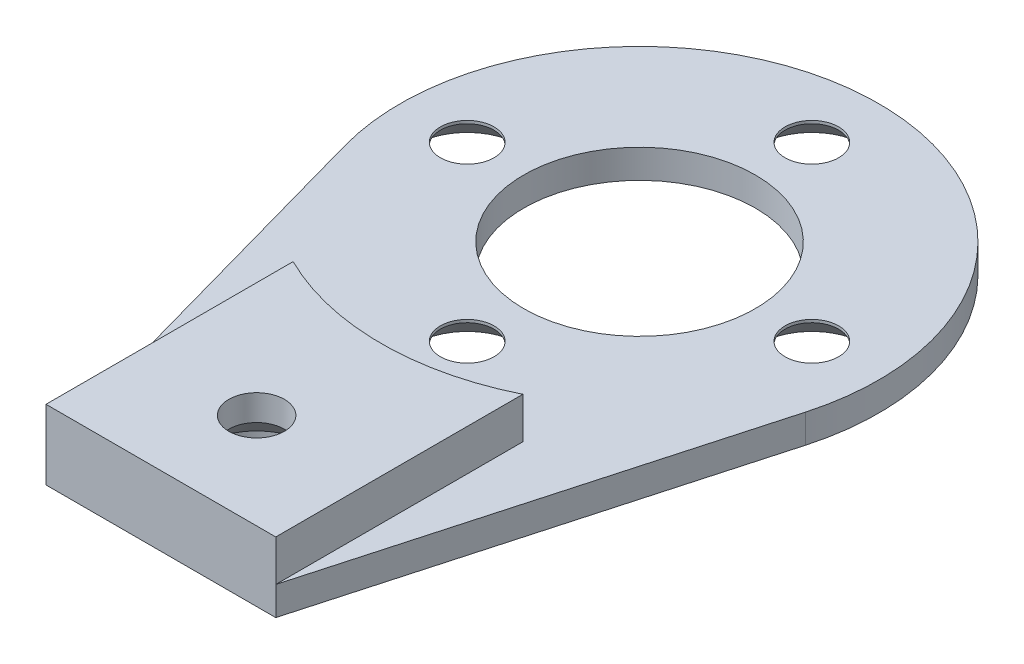
from build123d import *

# Parameters (mm, degrees)
BOSS_EXTRUDE1_DEPTH                               = 1.5
BOSS_EXTRUDE2_DEPTH                               = 2.15
CSK_FOR_M2_5_FLAT_HEAD_MACHINE_SCREW1_D           = 2.8
CSK_FOR_M2_5_FLAT_HEAD_MACHINE_SCREW1_CSINK_D     = 5.5
CSK_FOR_M2_5_FLAT_HEAD_MACHINE_SCREW1_CSINK_ANGLE = 90
SKETCH6_R                                         = 6.05
CUT_EXTRUDE1_DEPTH                                = 4.65
SKETCH7_R                                         = 2.75
CUT_EXTRUDE2_DEPTH                                = 1
CSK_FOR_M2_5_FLAT_HEAD_MACHINE_SCREW2_D           = 2.9
CSK_FOR_M2_5_FLAT_HEAD_MACHINE_SCREW2_DEPTH       = 8
CSK_FOR_M2_5_FLAT_HEAD_MACHINE_SCREW2_CSINK_D     = 5.5
CSK_FOR_M2_5_FLAT_HEAD_MACHINE_SCREW2_CSINK_ANGLE = 90
CSK_FOR_M2_5_FLAT_HEAD_MACHINE_SCREW2_TIP         = 0.871247898


with BuildPart() as part:
    # Sketch1 → Boss-Extrude1 (new body)
    with BuildSketch(Plane(origin=(0, 0, 0), x_dir=(1, 0, 0), z_dir=(0, 1, 0))):
        with BuildLine():
            Line((-12.039826938, -3.360441535), (-6, -25))
            Line((-6, -25), (6, -25))
            Line((6, -25), (12.039826938, -3.360441535))
            ThreePointArc((12.039826938, -3.360441535), (0, 12.5), (-12.039826938, -3.360441535))
        make_face()
    extrude(amount=BOSS_EXTRUDE1_DEPTH)

    # Sketch2 → Boss-Extrude2 (add)
    with BuildSketch(Plane(origin=(0, 1.5, 0), x_dir=(1, 0, 0), z_dir=(0, 1, 0))):
        with BuildLine():
            Line((-6, -25), (-6, -12.093386622))
            ThreePointArc((-6, -12.093386622), (0, -13.5), (6, -12.093386622))
            Line((6, -12.093386622), (6, -25))
            Line((6, -25), (-6, -25))
        make_face()
    extrude(amount=BOSS_EXTRUDE2_DEPTH)

    # CSK for M2.5 Flat Head Machine Screw1 (through all)
    with Locations(Plane(origin=(0, 0, 0), x_dir=(-1, 0, 0), z_dir=(0, -1, 0))):
        with Locations((0, -9), (9, 0), (0, 9), (-9, 0)):
            CounterSinkHole(CSK_FOR_M2_5_FLAT_HEAD_MACHINE_SCREW1_D / 2, CSK_FOR_M2_5_FLAT_HEAD_MACHINE_SCREW1_CSINK_D / 2, counter_sink_angle=CSK_FOR_M2_5_FLAT_HEAD_MACHINE_SCREW1_CSINK_ANGLE)

    # Sketch6 → Cut-Extrude1 (cut, through all)
    with BuildSketch(Plane.XZ):
        Circle(SKETCH6_R)
    extrude(amount=-CUT_EXTRUDE1_DEPTH, mode=Mode.SUBTRACT)

    # Sketch7 → Cut-Extrude2 (cut)
    with BuildSketch(Plane(origin=(0, 0, 0), x_dir=(-1, 0, 0), z_dir=(0, -1, 0))):
        with Locations((0, -20)):
            Circle(SKETCH7_R)
    extrude(amount=-CUT_EXTRUDE2_DEPTH, mode=Mode.SUBTRACT)

    # CSK for M2.5 Flat Head Machine Screw2
    with Locations(Plane(origin=(0, 1, 0), x_dir=(-1, 0, 0), z_dir=(0, -1, 0))):
        with Locations((0, -20)):
            CounterSinkHole(CSK_FOR_M2_5_FLAT_HEAD_MACHINE_SCREW2_D / 2, CSK_FOR_M2_5_FLAT_HEAD_MACHINE_SCREW2_CSINK_D / 2, depth=CSK_FOR_M2_5_FLAT_HEAD_MACHINE_SCREW2_DEPTH, counter_sink_angle=CSK_FOR_M2_5_FLAT_HEAD_MACHINE_SCREW2_CSINK_ANGLE)
            with Locations((0, 0, -(CSK_FOR_M2_5_FLAT_HEAD_MACHINE_SCREW2_DEPTH + CSK_FOR_M2_5_FLAT_HEAD_MACHINE_SCREW2_TIP / 2))):  # 118° drill point
                Cone(0, CSK_FOR_M2_5_FLAT_HEAD_MACHINE_SCREW2_D / 2, CSK_FOR_M2_5_FLAT_HEAD_MACHINE_SCREW2_TIP, mode=Mode.SUBTRACT)


solid = part.part
